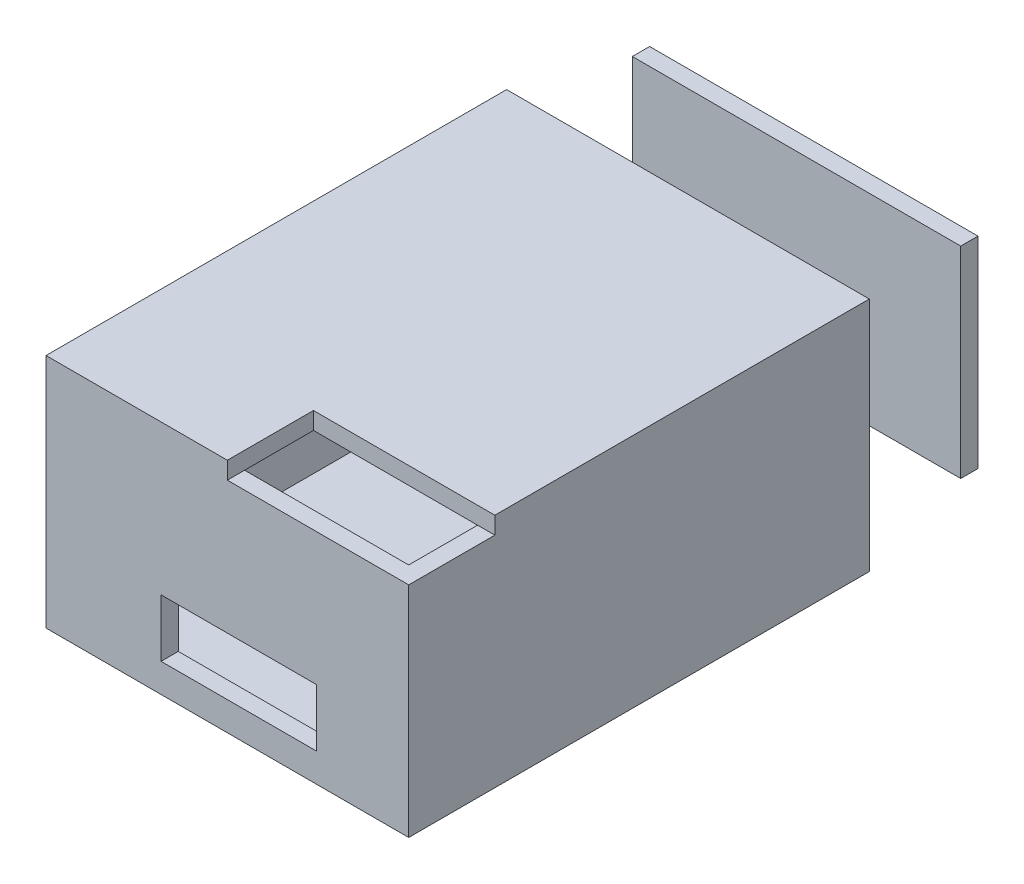
from build123d import *

# Parameters (mm, degrees)
ESBO_O2_W                = 63
ESBO_O2_H                = 80
RESSALTO_EXTRUS_O1_DEPTH = 3
RESSALTO_EXTRUS_O2_DEPTH = 35
ESBO_O4_W                = 63
ESBO_O4_H                = 65.041847247
RESSALTO_EXTRUS_O3_DEPTH = 3
ESBO_O6_W                = 57.038627548
ESBO_O6_H                = 34.967547607
RESSALTO_EXTRUS_O4_DEPTH = 3
RESSALTO_EXTRUS_O5_DEPTH = 3
ESBO_O8_W                = 26.997691041
ESBO_O8_H                = 10.002963711
CORTE_EXTRUS_O1_DEPTH    = 3


with BuildPart() as part:
    # Esboço2 → Ressalto-extrusão1 (new body)
    with BuildSketch(Plane(origin=(0, 0, 0), x_dir=(1, 0, 0), z_dir=(0, 1, 0))):
        with Locations((31.5, -40)):
            Rectangle(ESBO_O2_W, ESBO_O2_H)
    extrude(amount=RESSALTO_EXTRUS_O1_DEPTH)

    # Esboço3 → Ressalto-extrusão2 (add)
    with BuildSketch(Plane(origin=(0, 3, 0), x_dir=(1, 0, 0), z_dir=(0, 1, 0))):
        Polygon((63, -80), (63, 0), (60.001706293, 0), (60.001706293, -77.010558462), (2.99035903, -77.010558462), (2.99035903, 0), (0, 0), (0, -80), align=None)
    extrude(amount=RESSALTO_EXTRUS_O2_DEPTH)

    # Esboço4 → Ressalto-extrusão3 (add)
    with BuildSketch(Plane(origin=(0, 38, 0), x_dir=(1, 0, 0), z_dir=(0, 1, 0))):
        with Locations((31.5, -32.520923624)):
            Rectangle(ESBO_O4_W, ESBO_O4_H)
    extrude(amount=RESSALTO_EXTRUS_O3_DEPTH)

    # Esboço7 → Ressalto-extrusão5 (add)
    with BuildSketch(Plane(origin=(0, 38, 0), x_dir=(1, 0, 0), z_dir=(0, 1, 0))):
        Polygon((0, -65.041847247), (0, -80), (31.5, -80), (31.496032662, -65.041847247), align=None)
    extrude(amount=RESSALTO_EXTRUS_O5_DEPTH)

    # Esboço8 → Corte-extrusão1 (cut)
    with BuildSketch(Plane.XY.offset(80)):
        with Locations((33.481992584, 9.992269492)):
            Rectangle(ESBO_O8_W, ESBO_O8_H)
    extrude(amount=-CORTE_EXTRUS_O1_DEPTH, mode=Mode.SUBTRACT)


with BuildPart() as body_2:
    # Esboço6 → Ressalto-extrusão4 (new body)
    with BuildSketch(Plane(origin=(0, 0, -20), x_dir=(-1, 0, 0), z_dir=(0, 0, -1))):
        with Locations((-30.355722228, 19.414542594)):
            Rectangle(ESBO_O6_W, ESBO_O6_H)
    extrude(amount=RESSALTO_EXTRUS_O4_DEPTH)


solid = Compound([part.part, body_2.part])
